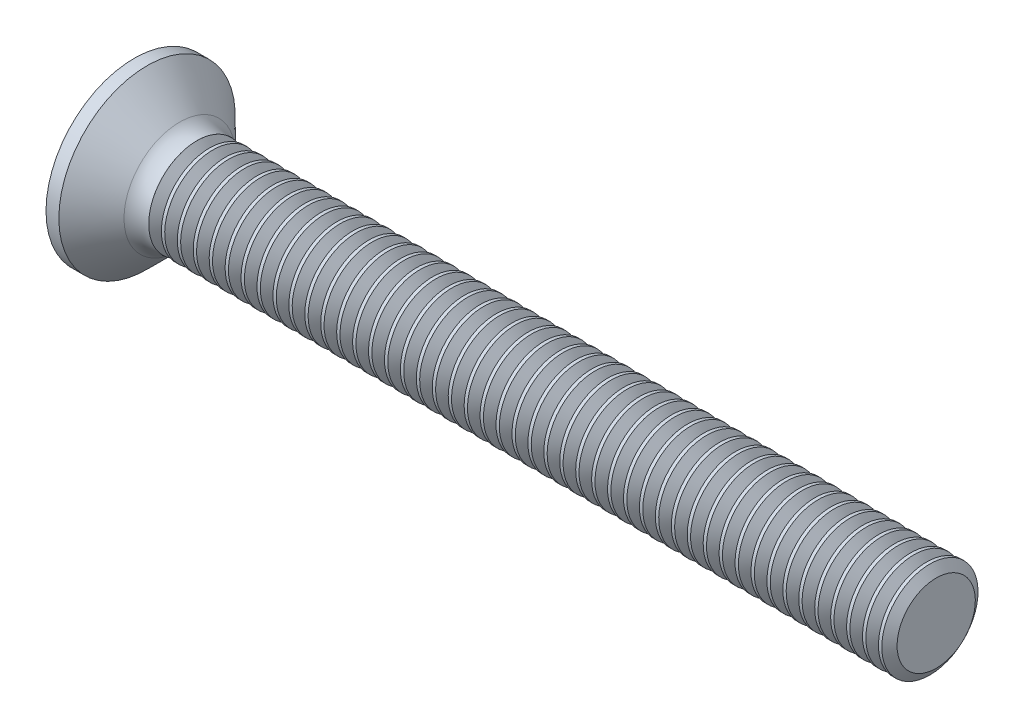
from build123d import *

# Parameters (mm, degrees)
FILLET1_R       = 0.8
SKETCH3_W       = 0.74
SKETCH3_H       = 3
SKETCH4_W       = 0.74
SKETCH4_H       = 0.99570227
RECPAT_COUNT    = 2
RECPAT_ANGLE    = 90
THDSCHPAT_COUNT = 47
THDSCHPAT_PITCH = 0.49673913


with BuildPart() as part:
    # BodySke → Base-Revolve (revolve)
    with BuildSketch(Plane.XY):
        Polygon((0, 0), (0, 2.75), (0.4, 2.75), (1.65, 1.5), (25, 1.5), (25, 0), align=None)
    revolve(axis=Axis((-6.35, 0, 0), (1, 0, 0)))

    # Fillet1
    fillet1_edges = [part.edges().sort_by_distance(p)[0] for p in [
        (1.65, -1.5, 0),
    ]]
    fillet(fillet1_edges, radius=FILLET1_R)

    # Sketch3 → Recess section 0
    with BuildSketch(Plane.ZY):
        Rectangle(SKETCH3_W, SKETCH3_H)
    # Sketch4 → Recess section 1
    with BuildSketch(Plane.ZY.offset(-2.01)):
        Rectangle(SKETCH4_W, SKETCH4_H)
    recess = loft(mode=Mode.SUBTRACT)

    # RecPat: Recess ×2 about axis
    recpat_axis = Axis((0, 0, 0), (1, 0, 0))
    for i in range(1, RECPAT_COUNT):
        add(recess.rotate(recpat_axis, i * RECPAT_ANGLE / (RECPAT_COUNT - 1)), mode=Mode.SUBTRACT)

    # RecCorSke → RecessCore (revolve, cut)
    with BuildSketch(Plane.XY):
        Polygon((0, 0), (0, 0.696552892), (2.01, 0.556), (2.190655351, 0), align=None)
    revolve(axis=Axis((-3.175, 0, 0), (1, 0, 0)), mode=Mode.SUBTRACT)

    # ThdSchSke → ThreadSchematic (revolve, cut)
    with BuildSketch(Plane.XY):
        Polygon((2.150001, -1.2195), (1.953592786, -1.5), (1.953592786, -1.875), (2.346409214, -1.875), (2.346409214, -1.5), align=None)
    threadschematic = revolve(axis=Axis((-3.175, 0, 0), (1, 0, 0)), mode=Mode.SUBTRACT)

    # ThdSchPat: ThreadSchematic ×47
    with Locations(*[(i * THDSCHPAT_PITCH, 0, 0) for i in range(1, THDSCHPAT_COUNT)]):
        add(threadschematic, mode=Mode.SUBTRACT)


solid = part.part
